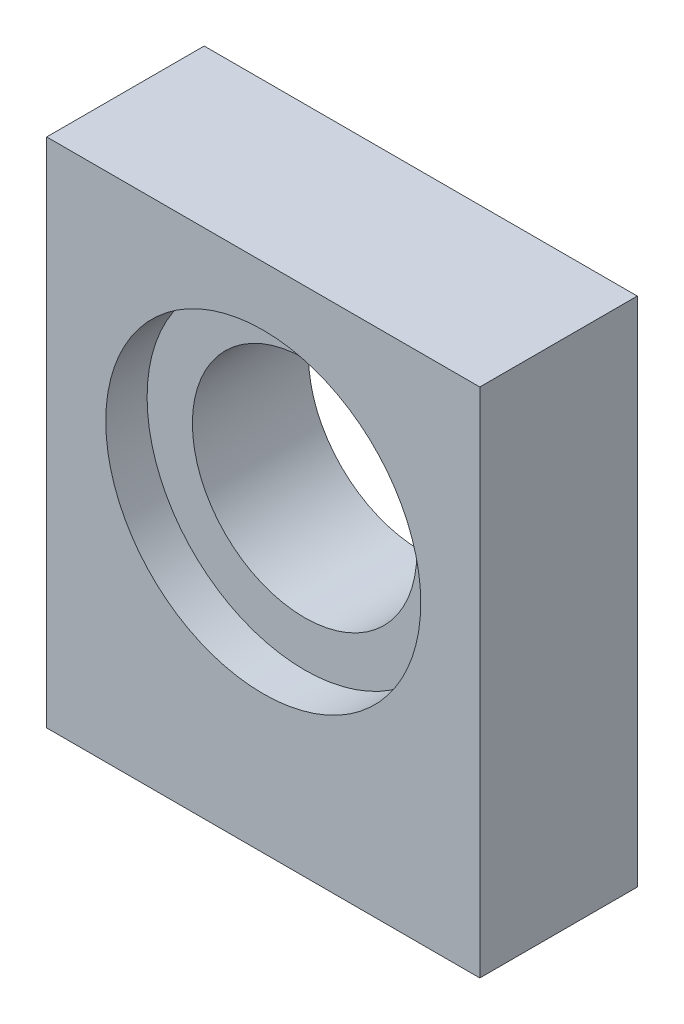
from build123d import *

# Parameters (mm, degrees)
SKETCH1_W                       = 22
SKETCH1_H                       = 26
SKETCH1_R                       = 5.7
BOSS_EXTRUDE1_DEPTH             = 8
SKETCH3_R                       = 8
CUT_EXTRUDE2_DEPTH              = 2.1
TAP_DRILL_FOR_M3X0_5_TAP1_D     = 2.5
TAP_DRILL_FOR_M3X0_5_TAP1_DEPTH = 5
TAP_DRILL_FOR_M3X0_5_TAP1_TIP   = 0.751075774


with BuildPart() as part:
    # Sketch1 → Boss-Extrude1 (new body)
    with BuildSketch(Plane.XY):
        with Locations((11, 13)):
            Rectangle(SKETCH1_W, SKETCH1_H)
        with Locations((11, 15)):
            Circle(SKETCH1_R, mode=Mode.SUBTRACT)
    extrude(amount=BOSS_EXTRUDE1_DEPTH)

    # Sketch3 → Cut-Extrude2 (cut)
    with BuildSketch(Plane(origin=(0, 0, 8), x_dir=(-1, 0, 0), z_dir=(0, 0, -1))):
        with Locations((-11, 15)):
            Circle(SKETCH3_R)
    extrude(amount=CUT_EXTRUDE2_DEPTH, mode=Mode.SUBTRACT)

    # Tap Drill for M3x0.5 Tap1
    with Locations(Plane(origin=(0, 0, 0), x_dir=(-1, 0, 0), z_dir=(0, -1, 0))):
        with Locations((-4, -5.5), (-18, -5.5), (-11, -2.5)):
            Hole(TAP_DRILL_FOR_M3X0_5_TAP1_D / 2, depth=TAP_DRILL_FOR_M3X0_5_TAP1_DEPTH)
            with Locations((0, 0, -(TAP_DRILL_FOR_M3X0_5_TAP1_DEPTH + TAP_DRILL_FOR_M3X0_5_TAP1_TIP / 2))):  # 118° drill point
                Cone(0, TAP_DRILL_FOR_M3X0_5_TAP1_D / 2, TAP_DRILL_FOR_M3X0_5_TAP1_TIP, mode=Mode.SUBTRACT)


solid = part.part
